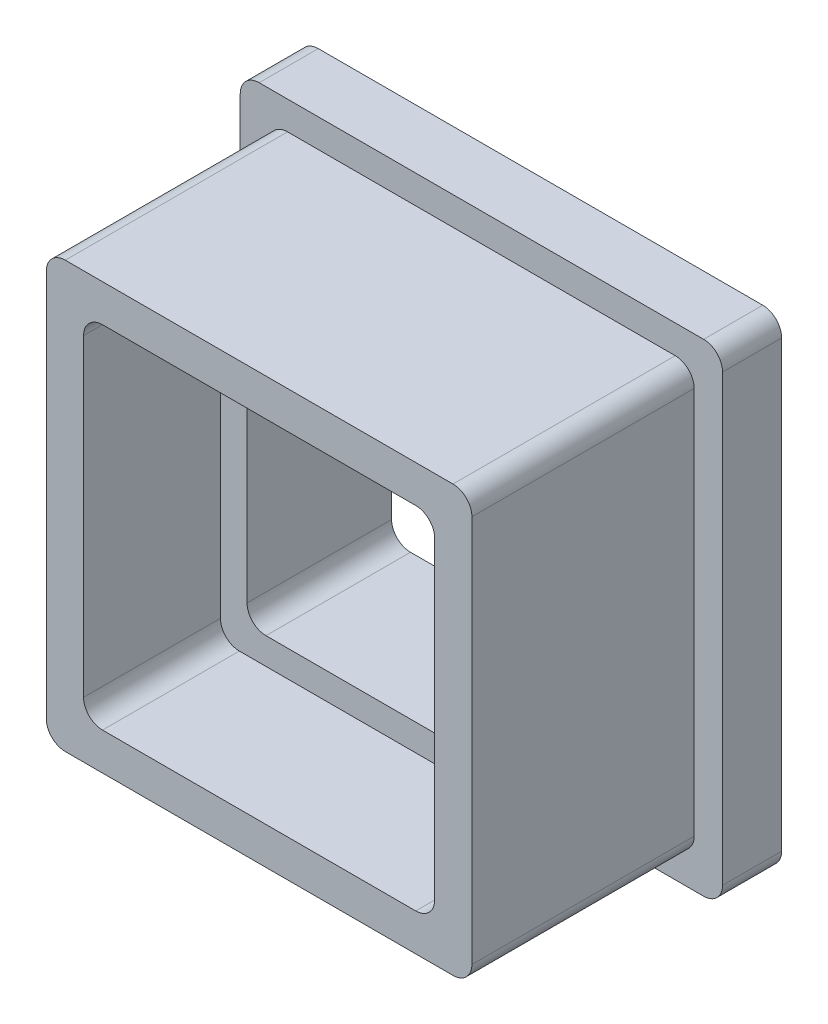
from build123d import *

# Parameters (mm, degrees)
SKETCH1_W                = 11.43
SKETCH1_H                = 11.43
BOSS_EXTRUDE1_DEPTH      = 4.7625
BOSS_EXTRUDE1_DEPTH_BACK = 1.5875
SKETCH2_W                = 12.954
SKETCH2_H                = 12.954
BOSS_EXTRUDE2_DEPTH      = 1.5875
SKETCH23_W               = 4.099999912
SKETCH23_H               = 3.500000096
CUT_EXTRUDE5_DEPTH       = 8.9375
SKETCH24_W               = 6.254
SKETCH24_H               = 4.754
CUT_EXTRUDE6_DEPTH       = 4.15
SKETCH25_W               = 9.43
SKETCH25_H               = 9.43
CUT_EXTRUDE7_DEPTH       = 4.056
SKETCH26_W               = 8
SKETCH26_H               = 8
CUT_EXTRUDE8_DEPTH       = 8.9375
FILLET7_R                = 0.508
CUT_EXTRUDE9_DEPTH       = 0.38


with BuildPart() as part:
    # Sketch1 → Boss-Extrude1 (new body, two sides)
    with BuildSketch(Plane.XY) as boss_extrude1_sk:
        Rectangle(SKETCH1_W, SKETCH1_H)
    extrude(amount=BOSS_EXTRUDE1_DEPTH)
    extrude(boss_extrude1_sk.sketch, amount=-BOSS_EXTRUDE1_DEPTH_BACK)

    # Sketch2 → Boss-Extrude2 (add)
    with BuildSketch(Plane(origin=(0, 0, -1.5875), x_dir=(-1, 0, 0), z_dir=(0, 0, -1))):
        Rectangle(SKETCH2_W, SKETCH2_H)
    extrude(amount=BOSS_EXTRUDE2_DEPTH)

    # Sketch23 → Cut-Extrude5 (cut, through all)
    with BuildSketch(Plane.XY.offset(4.7625)):
        Rectangle(SKETCH23_W, SKETCH23_H)
    extrude(amount=-CUT_EXTRUDE5_DEPTH, mode=Mode.SUBTRACT)

    # Sketch24 → Cut-Extrude6 (cut)
    with BuildSketch(Plane(origin=(0, 0, -3.175), x_dir=(-1, 0, 0), z_dir=(0, 0, -1))):
        Rectangle(SKETCH24_W, SKETCH24_H)
    extrude(amount=-CUT_EXTRUDE6_DEPTH, mode=Mode.SUBTRACT)

    # Sketch25 → Cut-Extrude7 (cut)
    with BuildSketch(Plane.XY.offset(4.7625)):
        Rectangle(SKETCH25_W, SKETCH25_H)
    extrude(amount=-CUT_EXTRUDE7_DEPTH, mode=Mode.SUBTRACT)

    # Sketch26 → Cut-Extrude8 (cut, through all)
    with BuildSketch(Plane(origin=(0, 0, -3.175), x_dir=(-1, 0, 0), z_dir=(0, 0, -1))):
        Rectangle(SKETCH26_W, SKETCH26_H)
    extrude(amount=-CUT_EXTRUDE8_DEPTH, mode=Mode.SUBTRACT)

    # Fillet7
    fillet7_edges = [part.edges().sort_by_distance(p)[0] for p in [
        (4, -4, -1.23425),
        (4, 4, -1.23425),
        (-4, 4, -1.23425),
        (-4, -4, -1.23425),
        (-6.477, 6.477, -2.38125),
        (6.477, 6.477, -2.38125),
        (6.477, -6.477, -2.38125),
        (-6.477, -6.477, -2.38125),
        (5.715, -5.715, 1.5875),
        (-5.715, -5.715, 1.5875),
        (-5.715, 5.715, 1.5875),
        (5.715, 5.715, 1.5875),
        (4.715, 4.715, 2.7345),
        (4.715, -4.715, 2.7345),
        (-4.715, -4.715, 2.7345),
        (-4.715, 4.715, 2.7345),
    ]]
    fillet(fillet7_edges, radius=FILLET7_R)

    # Sketch27 → Cut-Extrude9 (cut)
    with BuildSketch(Plane.XY.offset(4.7625)):
        with BuildLine():
            Line((-5.715, 5.207), (-5.715, -5.207))
            ThreePointArc((-5.715, -5.207), (-5.566210245, -5.566210245), (-5.207, -5.715))
            Line((-5.207, -5.715), (5.207, -5.715))
            ThreePointArc((5.207, -5.715), (5.566210245, -5.566210245), (5.715, -5.207))
            Line((5.715, -5.207), (5.715, 5.207))
            ThreePointArc((5.715, 5.207), (5.566210245, 5.566210245), (5.207, 5.715))
            Line((5.207, 5.715), (-5.207, 5.715))
            ThreePointArc((-5.207, 5.715), (-5.566210245, 5.566210245), (-5.715, 5.207))
        make_face()
    extrude(amount=-CUT_EXTRUDE9_DEPTH, mode=Mode.SUBTRACT)


solid = part.part
